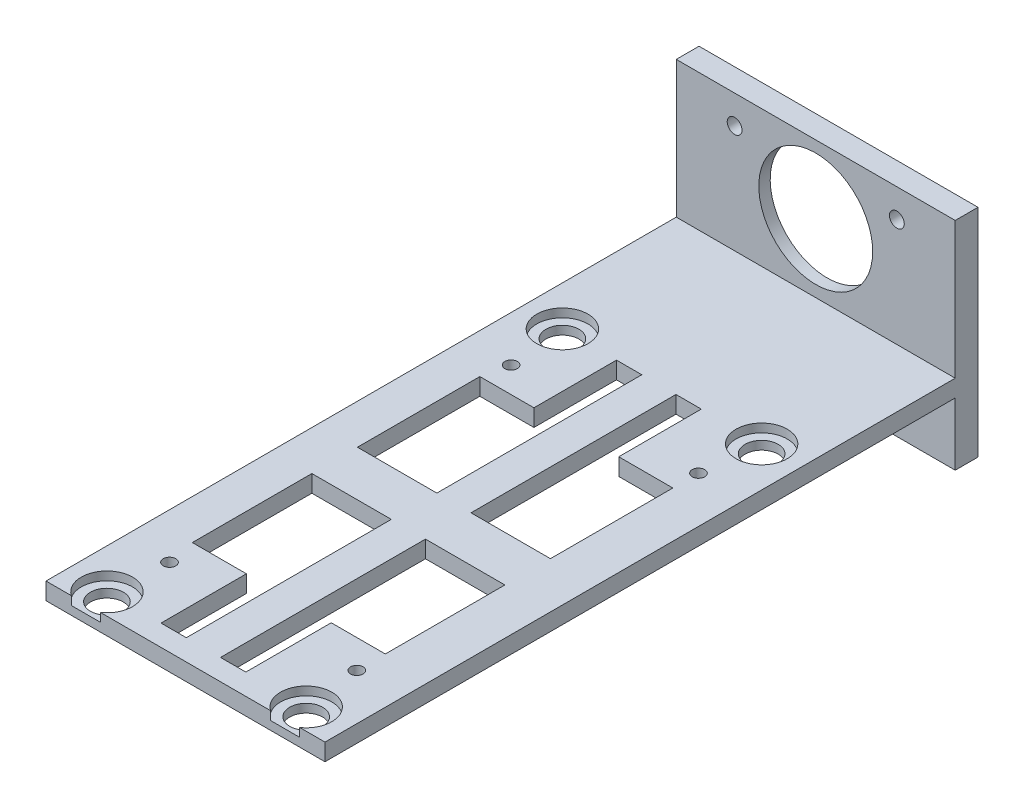
from build123d import *

# Parameters (mm, degrees)
SKETCH_1_R           = 2.9
SKETCH_1_R_2         = 1.1
EXTRUDE_1_DEPTH      = 3
SKETCH_2_R           = 4.5
CUT_EXTRUDE_1_DEPTH  = 1.5
SKETCH_3_W           = 49
SKETCH_3_H           = 4
EXTRUDE_2_DEPTH      = 24
EXTRUDE_2_DEPTH_BACK = 14
SKETCH_4_W           = 22
SKETCH_4_H           = 8
SKETCH_4_R           = 1.3
SKETCH_4_R_2         = 10
CUT_EXTRUDE_7_DEPTH  = 5
CUT_EXTRUDE_8_DEPTH  = 2


with BuildPart() as part:
    # 草图1 → 凸台-拉伸1 (new body)
    with BuildSketch(Plane(origin=(0, 0, 0), x_dir=(1, 0, 0), z_dir=(0, 1, 0))):
        Polygon((-42, 50.3), (-42, 3.3), (-42, -43.7), (0, -43.7), (7, -43.7), (7, 47), (7, 67), (-42, 67), align=None)
        with Locations((-35, -40)):
            Circle(SKETCH_1_R, mode=Mode.SUBTRACT)
        with Locations((-34, -30)):
            Circle(SKETCH_1_R_2, mode=Mode.SUBTRACT)
        Polygon((-35, -25), (-35, -4), (-21.05, -4), (-21.05, -40), (-25.5, -40), (-25.5, -25), align=None, mode=Mode.SUBTRACT)
        Polygon((-1.1, -4), (-1.1, -25), (-10.6, -25), (-10.6, -40), (-15.05, -40), (-15.05, -4), align=None, mode=Mode.SUBTRACT)
        with Locations((0, -40)):
            Circle(SKETCH_1_R, mode=Mode.SUBTRACT)
        with Locations((-1.1, -30)):
            Circle(SKETCH_1_R_2, mode=Mode.SUBTRACT)
        with Locations((-34, 30)):
            Circle(SKETCH_1_R_2, mode=Mode.SUBTRACT)
        Polygon((-21.05, 4), (-35, 4), (-35, 25.5), (-25.5, 25.5), (-25.5, 40), (-21.05, 40), align=None, mode=Mode.SUBTRACT)
        with Locations((-35, 40)):
            Circle(SKETCH_1_R, mode=Mode.SUBTRACT)
        Polygon((-10.6, 25.5), (-1.1, 25.5), (-1.1, 4), (-15.05, 4), (-15.05, 40), (-10.6, 40), align=None, mode=Mode.SUBTRACT)
        with Locations((-1.1, 30)):
            Circle(SKETCH_1_R_2, mode=Mode.SUBTRACT)
        with Locations((0, 40)):
            Circle(SKETCH_1_R, mode=Mode.SUBTRACT)
    extrude(amount=EXTRUDE_1_DEPTH)

    # 草图2 → 切除-拉伸1 (cut)
    with BuildSketch(Plane(origin=(0, 3, 0), x_dir=(1, 0, 0), z_dir=(0, 1, 0))):
        with Locations((-35, 40)):
            Circle(SKETCH_2_R)
        with Locations((0, 40)):
            Circle(SKETCH_2_R)
        with Locations((0, -40)):
            Circle(SKETCH_2_R)
        with Locations((-35, -40)):
            Circle(SKETCH_2_R)
    extrude(amount=-CUT_EXTRUDE_1_DEPTH, mode=Mode.SUBTRACT)

    # 草图3 → 凸台-拉伸2 (add, two sides)
    with BuildSketch(Plane(origin=(0, 3, 0), x_dir=(1, 0, 0), z_dir=(0, 1, 0))) as extrude_2_sk:
        with Locations((-17.5, 69)):
            Rectangle(SKETCH_3_W, SKETCH_3_H)
    extrude(amount=EXTRUDE_2_DEPTH)
    extrude(extrude_2_sk.sketch, amount=-EXTRUDE_2_DEPTH_BACK)

    # 草图4 → 切除-拉伸7 (cut, through all)
    with BuildSketch(Plane.XY.offset(-67)):
        with Locations((-17.95, -5.5)):
            Rectangle(SKETCH_4_W, SKETCH_4_H)
        with Locations((-31.75, 22)):
            Circle(SKETCH_4_R)
        with Locations((-3.25, 22)):
            Circle(SKETCH_4_R)
        with Locations((-2.75, -6.5)):
            Circle(SKETCH_4_R)
        with Locations((-32.25, -6.5)):
            Circle(SKETCH_4_R)
        with Locations((-17.5, 15)):
            Circle(SKETCH_4_R_2)
    extrude(amount=-CUT_EXTRUDE_7_DEPTH, mode=Mode.SUBTRACT)

    # 草图5 → 切除-拉伸8 (cut)
    with BuildSketch(Plane(origin=(0, 0, -71), x_dir=(-1, 0, 0), z_dir=(0, 0, -1))):
        Polygon((2.113595541, 22.631335811), (2.113595541, 23.270329273), (32.026158538, 23.270329273), (33.610999862, 23.270329273), (33.610999862, -7.824323718), (2.113595541, -7.824323718), align=None)
    extrude(amount=-CUT_EXTRUDE_8_DEPTH, mode=Mode.SUBTRACT)


solid = part.part
